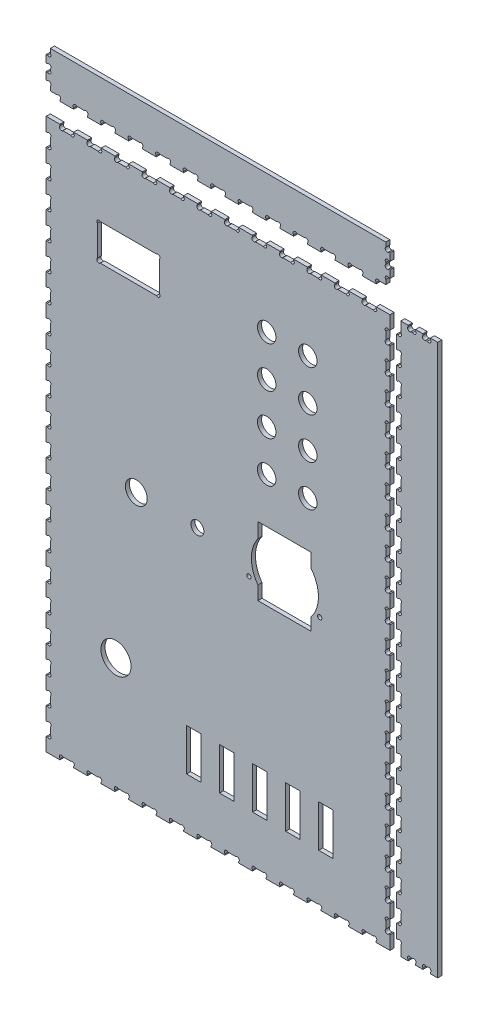
from build123d import *

# Parameters (mm, degrees)
CROQUIS2_W                = 251
CROQUIS2_H                = 402
CROQUIS2_R                = 11
CROQUIS2_R_2              = 1.55
CROQUIS2_R_3              = 4.75
CROQUIS2_R_4              = 8
CROQUIS2_R_5              = 6.75
CROQUIS2_W_2              = 10.6
CROQUIS2_H_2              = 30.7
SALIENTE_EXTRUIR2_DEPTH   = 3
CROQUIS4_W                = 3.05
CROQUIS4_H                = 9.804878049
CROQUIS4_H_2              = 9.804878048
CORTAR_EXTRUIR1_DEPTH     = 4
CROQUIS5_W                = 10.04
CROQUIS5_H                = 3.05
CORTAR_EXTRUIR2_DEPTH     = 4
CROQUIS12_W               = 30
CROQUIS12_H               = 402
SALIENTE_EXTRUIR3_DEPTH   = 3
CROQUIS12_W_2             = 251
CROQUIS12_H_2             = 30
SALIENTE_EXTRUIR3_2_DEPTH = 3
CROQUIS13_W               = 3.05
CROQUIS13_H               = 9.804878049
CROQUIS13_H_2             = 9.804878048
CORTAR_EXTRUIR8_DEPTH     = 4
CROQUIS14_W               = 5.39
CROQUIS14_H               = 3.05
CORTAR_EXTRUIR9_DEPTH     = 4
CROQUIS16_W               = 10.04
CROQUIS16_H               = 3.05
CORTAR_EXTRUIR10_DEPTH    = 4
CROQUIS18_W               = 3.05
CROQUIS18_H               = 5.39
CORTAR_EXTRUIR15_DEPTH    = 4
CROQUIS19_R               = 1.5
CORTAR_EXTRUIR12_DEPTH    = 4
CROQUIS20_R               = 1.5
CORTAR_EXTRUIR13_DEPTH    = 4
CROQUIS21_R               = 1.5
CORTAR_EXTRUIR14_DEPTH    = 4
CROQUIS23_R               = 1.5
CORTAR_EXTRUIR16_DEPTH    = 4
CROQUIS10_R               = 1.5
CORTAR_EXTRUIR6_DEPTH     = 4
CROQUIS11_R               = 1.5
CORTAR_EXTRUIR7_DEPTH     = 4


with BuildPart() as part:
    # Croquis2 → Saliente-Extruir2 (new body)
    with BuildSketch(Plane.XY):
        Rectangle(CROQUIS2_W, CROQUIS2_H)
        with Locations((-74.55, -116)):
            Circle(CROQUIS2_R, mode=Mode.SUBTRACT)
        with Locations((22.55, -15.8999)):
            Circle(CROQUIS2_R_2, mode=Mode.SUBTRACT)
        with Locations((74.25, -15.8999)):
            Circle(CROQUIS2_R_2, mode=Mode.SUBTRACT)
        with Locations((-15.0999, -4)):
            Circle(CROQUIS2_R_3, mode=Mode.SUBTRACT)
        with Locations((-59.72, -4)):
            Circle(CROQUIS2_R_4, mode=Mode.SUBTRACT)
        with Locations((65.5, 145)):
            Circle(CROQUIS2_R_5, mode=Mode.SUBTRACT)
        with Locations((35.5, 145)):
            Circle(CROQUIS2_R_5, mode=Mode.SUBTRACT)
        with Locations((35.5, 115)):
            Circle(CROQUIS2_R_5, mode=Mode.SUBTRACT)
        with Locations((65.5, 115)):
            Circle(CROQUIS2_R_5, mode=Mode.SUBTRACT)
        with Locations((35.5, 85)):
            Circle(CROQUIS2_R_5, mode=Mode.SUBTRACT)
        with Locations((65.5, 85)):
            Circle(CROQUIS2_R_5, mode=Mode.SUBTRACT)
        with Locations((35.5, 55)):
            Circle(CROQUIS2_R_5, mode=Mode.SUBTRACT)
        with Locations((65.5, 55)):
            Circle(CROQUIS2_R_5, mode=Mode.SUBTRACT)
        with Locations((-17.75, -148.35)):
            Rectangle(CROQUIS2_W_2, CROQUIS2_H_2, mode=Mode.SUBTRACT)
        with Locations((6.375, -148.35)):
            Rectangle(CROQUIS2_W_2, CROQUIS2_H_2, mode=Mode.SUBTRACT)
        with Locations((30.5, -148.35)):
            Rectangle(CROQUIS2_W_2, CROQUIS2_H_2, mode=Mode.SUBTRACT)
        with Locations((54.625, -148.35)):
            Rectangle(CROQUIS2_W_2, CROQUIS2_H_2, mode=Mode.SUBTRACT)
        with Locations((78.75, -148.35)):
            Rectangle(CROQUIS2_W_2, CROQUIS2_H_2, mode=Mode.SUBTRACT)
        with BuildLine():
            Line((29.1, 22), (67.7, 22))
            Line((67.7, 22), (67.7, 12.072751973))
            ThreePointArc((67.7, 12.072751973), (73.286, -3.5), (67.7, -19.072751973))
            Line((67.7, -19.072751973), (67.7, -28))
            Line((67.7, -28), (29.1, -28))
            Line((29.1, -28), (29.1, -18.084629032))
            ThreePointArc((29.1, -18.084629032), (24.286, -3.5), (29.1, 11.084629032))
            Line((29.1, 11.084629032), (29.1, 22))
        make_face(mode=Mode.SUBTRACT)
        with BuildLine():
            Line((-86.028579656, 154.1488), (-44.971220344, 154.1488))
            ThreePointArc((-44.971220344, 154.1488), (-42.8499, 154.1488), (-42.8499, 152.027479656))
            Line((-42.8499, 152.027479656), (-42.8499, 129.970120344))
            ThreePointArc((-42.8499, 129.970120344), (-42.8499, 127.8488), (-44.971220344, 127.8488))
            Line((-44.971220344, 127.8488), (-86.028579656, 127.8488))
            ThreePointArc((-86.028579656, 127.8488), (-88.1499, 127.8488), (-88.1499, 129.970120344))
            Line((-88.1499, 129.970120344), (-88.1499, 152.027479656))
            ThreePointArc((-88.1499, 152.027479656), (-88.1499, 154.1488), (-86.028579656, 154.1488))
        make_face(mode=Mode.SUBTRACT)
    extrude(amount=SALIENTE_EXTRUIR2_DEPTH)

    # Croquis4 → Cortar-Extruir1 (cut, through all)
    with BuildSketch(Plane.XY.offset(3)):
        with Locations((-123.975, 186.292682926)):
            Rectangle(CROQUIS4_W, CROQUIS4_H)
        with Locations((-123.975, 166.682926829)):
            Rectangle(CROQUIS4_W, CROQUIS4_H)
        with Locations((-123.975, 147.073170731)):
            Rectangle(CROQUIS4_W, CROQUIS4_H)
        with Locations((-123.975, 127.463414635)):
            Rectangle(CROQUIS4_W, CROQUIS4_H)
        with Locations((-123.975, 107.853658537)):
            Rectangle(CROQUIS4_W, CROQUIS4_H)
        with Locations((-123.975, 88.243902439)):
            Rectangle(CROQUIS4_W, CROQUIS4_H_2)
        with Locations((-123.975, 68.634146342)):
            Rectangle(CROQUIS4_W, CROQUIS4_H)
        with Locations((-123.975, 49.024390244)):
            Rectangle(CROQUIS4_W, CROQUIS4_H_2)
        with Locations((-123.975, 29.414634147)):
            Rectangle(CROQUIS4_W, CROQUIS4_H)
        with Locations((-123.975, 9.804878049)):
            Rectangle(CROQUIS4_W, CROQUIS4_H)
        with Locations((-123.975, -9.804878049)):
            Rectangle(CROQUIS4_W, CROQUIS4_H)
        with Locations((-123.975, -29.414634147)):
            Rectangle(CROQUIS4_W, CROQUIS4_H)
        with Locations((-123.975, -49.024390244)):
            Rectangle(CROQUIS4_W, CROQUIS4_H_2)
        with Locations((-123.975, -68.634146342)):
            Rectangle(CROQUIS4_W, CROQUIS4_H)
        with Locations((-123.975, -88.243902439)):
            Rectangle(CROQUIS4_W, CROQUIS4_H_2)
        with Locations((-123.975, -107.853658537)):
            Rectangle(CROQUIS4_W, CROQUIS4_H)
        with Locations((-123.975, -127.463414635)):
            Rectangle(CROQUIS4_W, CROQUIS4_H)
        with Locations((-123.975, -147.073170731)):
            Rectangle(CROQUIS4_W, CROQUIS4_H)
        with Locations((-123.975, -166.682926829)):
            Rectangle(CROQUIS4_W, CROQUIS4_H)
        with Locations((-123.975, -186.292682926)):
            Rectangle(CROQUIS4_W, CROQUIS4_H)
        with Locations((123.975, -186.292682926)):
            Rectangle(CROQUIS4_W, CROQUIS4_H)
        with Locations((123.975, -166.682926829)):
            Rectangle(CROQUIS4_W, CROQUIS4_H)
        with Locations((123.975, -147.073170731)):
            Rectangle(CROQUIS4_W, CROQUIS4_H)
        with Locations((123.975, -127.463414635)):
            Rectangle(CROQUIS4_W, CROQUIS4_H)
        with Locations((123.975, -107.853658537)):
            Rectangle(CROQUIS4_W, CROQUIS4_H)
        with Locations((123.975, -88.243902439)):
            Rectangle(CROQUIS4_W, CROQUIS4_H_2)
        with Locations((123.975, -68.634146342)):
            Rectangle(CROQUIS4_W, CROQUIS4_H)
        with Locations((123.975, -49.024390244)):
            Rectangle(CROQUIS4_W, CROQUIS4_H_2)
        with Locations((123.975, -29.414634147)):
            Rectangle(CROQUIS4_W, CROQUIS4_H)
        with Locations((123.975, -9.804878049)):
            Rectangle(CROQUIS4_W, CROQUIS4_H)
        with Locations((123.975, 9.804878049)):
            Rectangle(CROQUIS4_W, CROQUIS4_H)
        with Locations((123.975, 29.414634147)):
            Rectangle(CROQUIS4_W, CROQUIS4_H)
        with Locations((123.975, 49.024390244)):
            Rectangle(CROQUIS4_W, CROQUIS4_H_2)
        with Locations((123.975, 68.634146342)):
            Rectangle(CROQUIS4_W, CROQUIS4_H)
        with Locations((123.975, 88.243902439)):
            Rectangle(CROQUIS4_W, CROQUIS4_H_2)
        with Locations((123.975, 107.853658537)):
            Rectangle(CROQUIS4_W, CROQUIS4_H)
        with Locations((123.975, 127.463414635)):
            Rectangle(CROQUIS4_W, CROQUIS4_H)
        with Locations((123.975, 147.073170731)):
            Rectangle(CROQUIS4_W, CROQUIS4_H)
        with Locations((123.975, 166.682926829)):
            Rectangle(CROQUIS4_W, CROQUIS4_H)
        with Locations((123.975, 186.292682926)):
            Rectangle(CROQUIS4_W, CROQUIS4_H)
    extrude(amount=-CORTAR_EXTRUIR1_DEPTH, mode=Mode.SUBTRACT)

    # Croquis5 → Cortar-Extruir2 (cut, through all)
    with BuildSketch(Plane.XY.offset(3)):
        with Locations((-110.44, 199.475)):
            Rectangle(CROQUIS5_W, CROQUIS5_H)
        with Locations((-90.36, 199.475)):
            Rectangle(CROQUIS5_W, CROQUIS5_H)
        with Locations((-70.28, 199.475)):
            Rectangle(CROQUIS5_W, CROQUIS5_H)
        with Locations((-50.2, 199.475)):
            Rectangle(CROQUIS5_W, CROQUIS5_H)
        with Locations((-30.12, 199.475)):
            Rectangle(CROQUIS5_W, CROQUIS5_H)
        with Locations((-10.04, 199.475)):
            Rectangle(CROQUIS5_W, CROQUIS5_H)
        with Locations((10.04, 199.475)):
            Rectangle(CROQUIS5_W, CROQUIS5_H)
        with Locations((30.12, 199.475)):
            Rectangle(CROQUIS5_W, CROQUIS5_H)
        with Locations((50.2, 199.475)):
            Rectangle(CROQUIS5_W, CROQUIS5_H)
        with Locations((70.28, 199.475)):
            Rectangle(CROQUIS5_W, CROQUIS5_H)
        with Locations((90.36, 199.475)):
            Rectangle(CROQUIS5_W, CROQUIS5_H)
        with Locations((110.44, 199.475)):
            Rectangle(CROQUIS5_W, CROQUIS5_H)
        with Locations((110.44, -199.475)):
            Rectangle(CROQUIS5_W, CROQUIS5_H)
        with Locations((90.36, -199.475)):
            Rectangle(CROQUIS5_W, CROQUIS5_H)
        with Locations((70.28, -199.475)):
            Rectangle(CROQUIS5_W, CROQUIS5_H)
        with Locations((50.2, -199.475)):
            Rectangle(CROQUIS5_W, CROQUIS5_H)
        with Locations((30.12, -199.475)):
            Rectangle(CROQUIS5_W, CROQUIS5_H)
        with Locations((10.04, -199.475)):
            Rectangle(CROQUIS5_W, CROQUIS5_H)
        with Locations((-10.04, -199.475)):
            Rectangle(CROQUIS5_W, CROQUIS5_H)
        with Locations((-30.12, -199.475)):
            Rectangle(CROQUIS5_W, CROQUIS5_H)
        with Locations((-50.2, -199.475)):
            Rectangle(CROQUIS5_W, CROQUIS5_H)
        with Locations((-70.28, -199.475)):
            Rectangle(CROQUIS5_W, CROQUIS5_H)
        with Locations((-90.36, -199.475)):
            Rectangle(CROQUIS5_W, CROQUIS5_H)
        with Locations((-110.44, -199.475)):
            Rectangle(CROQUIS5_W, CROQUIS5_H)
    extrude(amount=-CORTAR_EXTRUIR2_DEPTH, mode=Mode.SUBTRACT)

    # Croquis10 → Cortar-Extruir6 (cut, through all)
    with BuildSketch(Plane.XY.offset(3)):
        with Locations((-123.510660172, 190.134461779)):
            Circle(CROQUIS10_R)
        with Locations((-123.510660172, 182.450904074)):
            Circle(CROQUIS10_R)
        with Locations((-123.510660172, 170.524705682)):
            Circle(CROQUIS10_R)
        with Locations((-123.510660172, 162.841147977)):
            Circle(CROQUIS10_R)
        with Locations((-123.510660172, 150.914949584)):
            Circle(CROQUIS10_R)
        with Locations((-123.510660172, 143.231391879)):
            Circle(CROQUIS10_R)
        with Locations((-123.510660172, 131.305193487)):
            Circle(CROQUIS10_R)
        with Locations((-123.510660172, 123.621635782)):
            Circle(CROQUIS10_R)
        with Locations((-123.510660172, 111.695437389)):
            Circle(CROQUIS10_R)
        with Locations((-123.510660172, 104.011879684)):
            Circle(CROQUIS10_R)
        with Locations((-123.510660172, 92.085681292)):
            Circle(CROQUIS10_R)
        with Locations((-123.510660172, 84.402123586)):
            Circle(CROQUIS10_R)
        with Locations((-123.510660172, 72.475925194)):
            Circle(CROQUIS10_R)
        with Locations((-123.510660172, 64.792367489)):
            Circle(CROQUIS10_R)
        with Locations((-123.510660172, 52.866169097)):
            Circle(CROQUIS10_R)
        with Locations((-123.510660172, 45.182611391)):
            Circle(CROQUIS10_R)
        with Locations((-123.510660172, 33.256412999)):
            Circle(CROQUIS10_R)
        with Locations((-123.510660172, 25.572855294)):
            Circle(CROQUIS10_R)
        with Locations((-123.510660172, 13.646656901)):
            Circle(CROQUIS10_R)
        with Locations((-123.510660172, 5.963099196)):
            Circle(CROQUIS10_R)
        with Locations((-123.510660172, -5.963099196)):
            Circle(CROQUIS10_R)
        with Locations((-123.510660172, -13.646656901)):
            Circle(CROQUIS10_R)
        with Locations((-123.510660172, -25.572855294)):
            Circle(CROQUIS10_R)
        with Locations((-123.510660172, -33.256412999)):
            Circle(CROQUIS10_R)
        with Locations((-123.510660172, -45.182611391)):
            Circle(CROQUIS10_R)
        with Locations((-123.510660172, -52.866169097)):
            Circle(CROQUIS10_R)
        with Locations((-123.510660172, -64.792367489)):
            Circle(CROQUIS10_R)
        with Locations((-123.510660172, -72.475925194)):
            Circle(CROQUIS10_R)
        with Locations((-123.510660172, -84.402123586)):
            Circle(CROQUIS10_R)
        with Locations((-123.510660172, -92.085681292)):
            Circle(CROQUIS10_R)
        with Locations((-123.510660172, -104.011879684)):
            Circle(CROQUIS10_R)
        with Locations((-123.510660172, -111.695437389)):
            Circle(CROQUIS10_R)
        with Locations((-123.510660172, -123.621635782)):
            Circle(CROQUIS10_R)
        with Locations((-123.510660172, -131.305193487)):
            Circle(CROQUIS10_R)
        with Locations((-123.510660172, -143.231391879)):
            Circle(CROQUIS10_R)
        with Locations((-123.510660172, -150.914949584)):
            Circle(CROQUIS10_R)
        with Locations((-123.510660172, -162.841147977)):
            Circle(CROQUIS10_R)
        with Locations((-123.510660172, -170.524705682)):
            Circle(CROQUIS10_R)
        with Locations((-123.510660172, -182.450904074)):
            Circle(CROQUIS10_R)
        with Locations((-123.510660172, -190.134461779)):
            Circle(CROQUIS10_R)
        with Locations((123.510660172, -190.134461779)):
            Circle(CROQUIS10_R)
        with Locations((123.510660172, -182.450904074)):
            Circle(CROQUIS10_R)
        with Locations((123.510660172, -170.524705682)):
            Circle(CROQUIS10_R)
        with Locations((123.510660172, -162.841147977)):
            Circle(CROQUIS10_R)
        with Locations((123.510660172, -150.914949584)):
            Circle(CROQUIS10_R)
        with Locations((123.510660172, -143.231391879)):
            Circle(CROQUIS10_R)
        with Locations((123.510660172, -131.305193487)):
            Circle(CROQUIS10_R)
        with Locations((123.510660172, -123.621635782)):
            Circle(CROQUIS10_R)
        with Locations((123.510660172, -111.695437389)):
            Circle(CROQUIS10_R)
        with Locations((123.510660172, -104.011879684)):
            Circle(CROQUIS10_R)
        with Locations((123.510660172, -92.085681292)):
            Circle(CROQUIS10_R)
        with Locations((123.510660172, -84.402123586)):
            Circle(CROQUIS10_R)
        with Locations((123.510660172, -72.475925194)):
            Circle(CROQUIS10_R)
        with Locations((123.510660172, -64.792367489)):
            Circle(CROQUIS10_R)
        with Locations((123.510660172, -52.866169097)):
            Circle(CROQUIS10_R)
        with Locations((123.510660172, -45.182611391)):
            Circle(CROQUIS10_R)
        with Locations((123.510660172, -33.256412999)):
            Circle(CROQUIS10_R)
        with Locations((123.510660172, -25.572855294)):
            Circle(CROQUIS10_R)
        with Locations((123.510660172, -13.646656901)):
            Circle(CROQUIS10_R)
        with Locations((123.510660172, -5.963099196)):
            Circle(CROQUIS10_R)
        with Locations((123.510660172, 5.963099196)):
            Circle(CROQUIS10_R)
        with Locations((123.510660172, 13.646656901)):
            Circle(CROQUIS10_R)
        with Locations((123.510660172, 25.572855294)):
            Circle(CROQUIS10_R)
        with Locations((123.510660172, 33.256412999)):
            Circle(CROQUIS10_R)
        with Locations((123.510660172, 45.182611391)):
            Circle(CROQUIS10_R)
        with Locations((123.510660172, 52.866169097)):
            Circle(CROQUIS10_R)
        with Locations((123.510660172, 64.792367489)):
            Circle(CROQUIS10_R)
        with Locations((123.510660172, 72.475925194)):
            Circle(CROQUIS10_R)
        with Locations((123.510660172, 84.402123586)):
            Circle(CROQUIS10_R)
        with Locations((123.510660172, 92.085681292)):
            Circle(CROQUIS10_R)
        with Locations((123.510660172, 104.011879684)):
            Circle(CROQUIS10_R)
        with Locations((123.510660172, 111.695437389)):
            Circle(CROQUIS10_R)
        with Locations((123.510660172, 123.621635782)):
            Circle(CROQUIS10_R)
        with Locations((123.510660172, 131.305193487)):
            Circle(CROQUIS10_R)
        with Locations((123.510660172, 143.231391879)):
            Circle(CROQUIS10_R)
        with Locations((123.510660172, 150.914949584)):
            Circle(CROQUIS10_R)
        with Locations((123.510660172, 162.841147977)):
            Circle(CROQUIS10_R)
        with Locations((123.510660172, 170.524705682)):
            Circle(CROQUIS10_R)
        with Locations((123.510660172, 182.450904074)):
            Circle(CROQUIS10_R)
        with Locations((123.510660172, 190.134461779)):
            Circle(CROQUIS10_R)
    extrude(amount=-CORTAR_EXTRUIR6_DEPTH, mode=Mode.SUBTRACT)

    # Croquis11 → Cortar-Extruir7 (cut, through all)
    with BuildSketch(Plane.XY.offset(3)):
        with Locations((-114.399339828, 199.010660172)):
            Circle(CROQUIS11_R)
        with Locations((-106.480660172, 199.010660172)):
            Circle(CROQUIS11_R)
        with Locations((-94.319339828, 199.010660172)):
            Circle(CROQUIS11_R)
        with Locations((-86.400660172, 199.010660172)):
            Circle(CROQUIS11_R)
        with Locations((-74.239339828, 199.010660172)):
            Circle(CROQUIS11_R)
        with Locations((-66.320660172, 199.010660172)):
            Circle(CROQUIS11_R)
        with Locations((-54.159339828, 199.010660172)):
            Circle(CROQUIS11_R)
        with Locations((-46.240660172, 199.010660172)):
            Circle(CROQUIS11_R)
        with Locations((-34.079339828, 199.010660172)):
            Circle(CROQUIS11_R)
        with Locations((-26.160660172, 199.010660172)):
            Circle(CROQUIS11_R)
        with Locations((-13.999339828, 199.010660172)):
            Circle(CROQUIS11_R)
        with Locations((-6.080660172, 199.010660172)):
            Circle(CROQUIS11_R)
        with Locations((6.080660172, 199.010660172)):
            Circle(CROQUIS11_R)
        with Locations((13.999339828, 199.010660172)):
            Circle(CROQUIS11_R)
        with Locations((26.160660172, 199.010660172)):
            Circle(CROQUIS11_R)
        with Locations((34.079339828, 199.010660172)):
            Circle(CROQUIS11_R)
        with Locations((46.240660172, 199.010660172)):
            Circle(CROQUIS11_R)
        with Locations((54.159339828, 199.010660172)):
            Circle(CROQUIS11_R)
        with Locations((66.320660172, 199.010660172)):
            Circle(CROQUIS11_R)
        with Locations((74.239339828, 199.010660172)):
            Circle(CROQUIS11_R)
        with Locations((86.400660172, 199.010660172)):
            Circle(CROQUIS11_R)
        with Locations((94.319339828, 199.010660172)):
            Circle(CROQUIS11_R)
        with Locations((106.480660172, 199.010660172)):
            Circle(CROQUIS11_R)
        with Locations((114.399339828, 199.010660172)):
            Circle(CROQUIS11_R)
        with Locations((114.399339828, -199.010660172)):
            Circle(CROQUIS11_R)
        with Locations((106.480660172, -199.010660172)):
            Circle(CROQUIS11_R)
        with Locations((94.319339828, -199.010660172)):
            Circle(CROQUIS11_R)
        with Locations((86.400660172, -199.010660172)):
            Circle(CROQUIS11_R)
        with Locations((74.239339828, -199.010660172)):
            Circle(CROQUIS11_R)
        with Locations((66.320660172, -199.010660172)):
            Circle(CROQUIS11_R)
        with Locations((54.159339828, -199.010660172)):
            Circle(CROQUIS11_R)
        with Locations((46.240660172, -199.010660172)):
            Circle(CROQUIS11_R)
        with Locations((34.079339828, -199.010660172)):
            Circle(CROQUIS11_R)
        with Locations((26.160660172, -199.010660172)):
            Circle(CROQUIS11_R)
        with Locations((13.999339828, -199.010660172)):
            Circle(CROQUIS11_R)
        with Locations((6.080660172, -199.010660172)):
            Circle(CROQUIS11_R)
        with Locations((-6.080660172, -199.010660172)):
            Circle(CROQUIS11_R)
        with Locations((-13.999339828, -199.010660172)):
            Circle(CROQUIS11_R)
        with Locations((-26.160660172, -199.010660172)):
            Circle(CROQUIS11_R)
        with Locations((-34.079339828, -199.010660172)):
            Circle(CROQUIS11_R)
        with Locations((-46.240660172, -199.010660172)):
            Circle(CROQUIS11_R)
        with Locations((-54.159339828, -199.010660172)):
            Circle(CROQUIS11_R)
        with Locations((-66.320660172, -199.010660172)):
            Circle(CROQUIS11_R)
        with Locations((-74.239339828, -199.010660172)):
            Circle(CROQUIS11_R)
        with Locations((-86.400660172, -199.010660172)):
            Circle(CROQUIS11_R)
        with Locations((-94.319339828, -199.010660172)):
            Circle(CROQUIS11_R)
        with Locations((-106.480660172, -199.010660172)):
            Circle(CROQUIS11_R)
        with Locations((-114.399339828, -199.010660172)):
            Circle(CROQUIS11_R)
    extrude(amount=-CORTAR_EXTRUIR7_DEPTH, mode=Mode.SUBTRACT)


with BuildPart() as body_2:
    # Croquis12 → Saliente-Extruir3 (new body)
    with BuildSketch(Plane.XY):
        with Locations((145.366831222, 0)):
            Rectangle(CROQUIS12_W, CROQUIS12_H)
    extrude(amount=SALIENTE_EXTRUIR3_DEPTH)

    # Croquis13 → Cortar-Extruir8 (cut, through all)
    with BuildSketch(Plane.XY.offset(3)):
        with Locations((131.891831222, 196.097560976)):
            Rectangle(CROQUIS13_W, CROQUIS13_H)
        with Locations((131.891831222, 176.487804878)):
            Rectangle(CROQUIS13_W, CROQUIS13_H_2)
        with Locations((131.891831222, 156.878048781)):
            Rectangle(CROQUIS13_W, CROQUIS13_H)
        with Locations((131.891831222, 137.268292683)):
            Rectangle(CROQUIS13_W, CROQUIS13_H_2)
        with Locations((131.891831222, 117.658536586)):
            Rectangle(CROQUIS13_W, CROQUIS13_H)
        with Locations((131.891831222, 98.048780488)):
            Rectangle(CROQUIS13_W, CROQUIS13_H)
        with Locations((131.891831222, 78.439024391)):
            Rectangle(CROQUIS13_W, CROQUIS13_H)
        with Locations((131.891831222, 58.829268293)):
            Rectangle(CROQUIS13_W, CROQUIS13_H)
        with Locations((131.891831222, 39.219512196)):
            Rectangle(CROQUIS13_W, CROQUIS13_H)
        with Locations((131.891831222, 19.609756098)):
            Rectangle(CROQUIS13_W, CROQUIS13_H)
        with Locations((131.891831222, 0)):
            Rectangle(CROQUIS13_W, CROQUIS13_H_2)
        with Locations((131.891831222, -19.609756098)):
            Rectangle(CROQUIS13_W, CROQUIS13_H)
        with Locations((131.891831222, -39.219512196)):
            Rectangle(CROQUIS13_W, CROQUIS13_H)
        with Locations((131.891831222, -58.829268293)):
            Rectangle(CROQUIS13_W, CROQUIS13_H)
        with Locations((131.891831222, -78.439024391)):
            Rectangle(CROQUIS13_W, CROQUIS13_H)
        with Locations((131.891831222, -98.048780488)):
            Rectangle(CROQUIS13_W, CROQUIS13_H)
        with Locations((131.891831222, -117.658536586)):
            Rectangle(CROQUIS13_W, CROQUIS13_H)
        with Locations((131.891831222, -137.268292683)):
            Rectangle(CROQUIS13_W, CROQUIS13_H_2)
        with Locations((131.891831222, -156.878048781)):
            Rectangle(CROQUIS13_W, CROQUIS13_H)
        with Locations((131.891831222, -176.487804878)):
            Rectangle(CROQUIS13_W, CROQUIS13_H_2)
        with Locations((131.891831222, -196.097560976)):
            Rectangle(CROQUIS13_W, CROQUIS13_H)
    extrude(amount=-CORTAR_EXTRUIR8_DEPTH, mode=Mode.SUBTRACT)

    # Croquis14 → Cortar-Extruir9 (cut, through all)
    with BuildSketch(Plane.XY.offset(3)):
        with Locations((141.501831222, 199.475)):
            Rectangle(CROQUIS14_W, CROQUIS14_H)
        with Locations((152.281831222, 199.475)):
            Rectangle(CROQUIS14_W, CROQUIS14_H)
        with Locations((152.281831222, -199.475)):
            Rectangle(CROQUIS14_W, CROQUIS14_H)
        with Locations((141.501831222, -199.475)):
            Rectangle(CROQUIS14_W, CROQUIS14_H)
    extrude(amount=-CORTAR_EXTRUIR9_DEPTH, mode=Mode.SUBTRACT)

    # Croquis19 → Cortar-Extruir12 (cut, through all)
    with BuildSketch(Plane.XY.offset(3)):
        with Locations((132.356171051, 192.255782123)):
            Circle(CROQUIS19_R)
        with Locations((132.356171051, 180.329583731)):
            Circle(CROQUIS19_R)
        with Locations((132.356171051, 172.646026025)):
            Circle(CROQUIS19_R)
        with Locations((132.356171051, 160.719827633)):
            Circle(CROQUIS19_R)
        with Locations((132.356171051, 153.036269928)):
            Circle(CROQUIS19_R)
        with Locations((132.356171051, 141.110071536)):
            Circle(CROQUIS19_R)
        with Locations((132.356171051, 133.42651383)):
            Circle(CROQUIS19_R)
        with Locations((132.356171051, 121.500315438)):
            Circle(CROQUIS19_R)
        with Locations((132.356171051, 113.816757733)):
            Circle(CROQUIS19_R)
        with Locations((132.356171051, 101.89055934)):
            Circle(CROQUIS19_R)
        with Locations((132.356171051, 94.207001635)):
            Circle(CROQUIS19_R)
        with Locations((132.356171051, 82.280803243)):
            Circle(CROQUIS19_R)
        with Locations((132.356171051, 74.597245538)):
            Circle(CROQUIS19_R)
        with Locations((132.356171051, 62.671047145)):
            Circle(CROQUIS19_R)
        with Locations((132.356171051, 54.98748944)):
            Circle(CROQUIS19_R)
        with Locations((132.356171051, 43.061291048)):
            Circle(CROQUIS19_R)
        with Locations((132.356171051, 35.377733343)):
            Circle(CROQUIS19_R)
        with Locations((132.356171051, 23.45153495)):
            Circle(CROQUIS19_R)
        with Locations((132.356171051, 15.767977245)):
            Circle(CROQUIS19_R)
        with Locations((132.356171051, 3.841778853)):
            Circle(CROQUIS19_R)
        with Locations((132.356171051, -3.841778853)):
            Circle(CROQUIS19_R)
        with Locations((132.356171051, -15.767977245)):
            Circle(CROQUIS19_R)
        with Locations((132.356171051, -23.45153495)):
            Circle(CROQUIS19_R)
        with Locations((132.356171051, -35.377733343)):
            Circle(CROQUIS19_R)
        with Locations((132.356171051, -43.061291048)):
            Circle(CROQUIS19_R)
        with Locations((132.356171051, -54.98748944)):
            Circle(CROQUIS19_R)
        with Locations((132.356171051, -62.671047145)):
            Circle(CROQUIS19_R)
        with Locations((132.356171051, -74.597245538)):
            Circle(CROQUIS19_R)
        with Locations((132.356171051, -82.280803243)):
            Circle(CROQUIS19_R)
        with Locations((132.356171051, -94.207001635)):
            Circle(CROQUIS19_R)
        with Locations((132.356171051, -101.89055934)):
            Circle(CROQUIS19_R)
        with Locations((132.356171051, -113.816757733)):
            Circle(CROQUIS19_R)
        with Locations((132.356171051, -121.500315438)):
            Circle(CROQUIS19_R)
        with Locations((132.356171051, -133.42651383)):
            Circle(CROQUIS19_R)
        with Locations((132.356171051, -141.110071536)):
            Circle(CROQUIS19_R)
        with Locations((132.356171051, -153.036269928)):
            Circle(CROQUIS19_R)
        with Locations((132.356171051, -160.719827633)):
            Circle(CROQUIS19_R)
        with Locations((132.356171051, -172.646026025)):
            Circle(CROQUIS19_R)
        with Locations((132.356171051, -180.329583731)):
            Circle(CROQUIS19_R)
        with Locations((132.356171051, -192.255782123)):
            Circle(CROQUIS19_R)
    extrude(amount=-CORTAR_EXTRUIR12_DEPTH, mode=Mode.SUBTRACT)

    # Croquis20 → Cortar-Extruir13 (cut, through all)
    with BuildSketch(Plane.XY.offset(3)):
        with Locations((139.867491394, 199.010660172)):
            Circle(CROQUIS20_R)
        with Locations((143.136171051, 199.010660172)):
            Circle(CROQUIS20_R)
        with Locations((153.916171051, 199.010660172)):
            Circle(CROQUIS20_R)
        with Locations((150.647491394, 199.010660172)):
            Circle(CROQUIS20_R)
        with Locations((153.916171051, -199.010660172)):
            Circle(CROQUIS20_R)
        with Locations((150.647491394, -199.010660172)):
            Circle(CROQUIS20_R)
        with Locations((139.867491394, -199.010660172)):
            Circle(CROQUIS20_R)
        with Locations((143.136171051, -199.010660172)):
            Circle(CROQUIS20_R)
    extrude(amount=-CORTAR_EXTRUIR13_DEPTH, mode=Mode.SUBTRACT)


with BuildPart() as body_3:
    # Croquis12 → Saliente-Extruir3 2 (new body)
    with BuildSketch(Plane.XY):
        with Locations((0, 230.459584674)):
            Rectangle(CROQUIS12_W_2, CROQUIS12_H_2)
    extrude(amount=SALIENTE_EXTRUIR3_2_DEPTH)

    # Croquis16 → Cortar-Extruir10 (cut, through all)
    with BuildSketch(Plane.XY.offset(3)):
        with Locations((-120.48, 216.984584674)):
            Rectangle(CROQUIS16_W, CROQUIS16_H)
        with Locations((-100.4, 216.984584674)):
            Rectangle(CROQUIS16_W, CROQUIS16_H)
        with Locations((-80.32, 216.984584674)):
            Rectangle(CROQUIS16_W, CROQUIS16_H)
        with Locations((-60.24, 216.984584674)):
            Rectangle(CROQUIS16_W, CROQUIS16_H)
        with Locations((-40.16, 216.984584674)):
            Rectangle(CROQUIS16_W, CROQUIS16_H)
        with Locations((-20.08, 216.984584674)):
            Rectangle(CROQUIS16_W, CROQUIS16_H)
        with Locations((0, 216.984584674)):
            Rectangle(CROQUIS16_W, CROQUIS16_H)
        with Locations((20.08, 216.984584674)):
            Rectangle(CROQUIS16_W, CROQUIS16_H)
        with Locations((40.16, 216.984584674)):
            Rectangle(CROQUIS16_W, CROQUIS16_H)
        with Locations((60.24, 216.984584674)):
            Rectangle(CROQUIS16_W, CROQUIS16_H)
        with Locations((80.32, 216.984584674)):
            Rectangle(CROQUIS16_W, CROQUIS16_H)
        with Locations((100.4, 216.984584674)):
            Rectangle(CROQUIS16_W, CROQUIS16_H)
        with Locations((120.48, 216.984584674)):
            Rectangle(CROQUIS16_W, CROQUIS16_H)
    extrude(amount=-CORTAR_EXTRUIR10_DEPTH, mode=Mode.SUBTRACT)

    # Croquis18 → Cortar-Extruir15 (cut, through all)
    with BuildSketch(Plane.XY.offset(3)):
        with Locations((123.975, 221.204584674)):
            Rectangle(CROQUIS18_W, CROQUIS18_H)
        with Locations((123.975, 242.764584674)):
            Rectangle(CROQUIS18_W, CROQUIS18_H)
        with Locations((123.975, 231.984584674)):
            Rectangle(CROQUIS18_W, CROQUIS18_H)
        with Locations((-123.975, 231.984584674)):
            Rectangle(CROQUIS18_W, CROQUIS18_H)
        with Locations((-123.975, 242.764584674)):
            Rectangle(CROQUIS18_W, CROQUIS18_H)
        with Locations((-123.975, 221.204584674)):
            Rectangle(CROQUIS18_W, CROQUIS18_H)
    extrude(amount=-CORTAR_EXTRUIR15_DEPTH, mode=Mode.SUBTRACT)

    # Croquis21 → Cortar-Extruir14 (cut, through all)
    with BuildSketch(Plane.XY.offset(3)):
        with Locations((-116.520660172, 217.448924502)):
            Circle(CROQUIS21_R)
        with Locations((-104.359339828, 217.448924502)):
            Circle(CROQUIS21_R)
        with Locations((-96.440660172, 217.448924502)):
            Circle(CROQUIS21_R)
        with Locations((-76.360660172, 217.448924502)):
            Circle(CROQUIS21_R)
        with Locations((-84.279339828, 217.448924502)):
            Circle(CROQUIS21_R)
        with Locations((-56.280660172, 217.448924502)):
            Circle(CROQUIS21_R)
        with Locations((-64.199339828, 217.448924502)):
            Circle(CROQUIS21_R)
        with Locations((-36.200660172, 217.448924502)):
            Circle(CROQUIS21_R)
        with Locations((-44.119339828, 217.448924502)):
            Circle(CROQUIS21_R)
        with Locations((-16.120660172, 217.448924502)):
            Circle(CROQUIS21_R)
        with Locations((-24.039339828, 217.448924502)):
            Circle(CROQUIS21_R)
        with Locations((3.959339828, 217.448924502)):
            Circle(CROQUIS21_R)
        with Locations((-3.959339828, 217.448924502)):
            Circle(CROQUIS21_R)
        with Locations((24.039339828, 217.448924502)):
            Circle(CROQUIS21_R)
        with Locations((16.120660172, 217.448924502)):
            Circle(CROQUIS21_R)
        with Locations((44.119339828, 217.448924502)):
            Circle(CROQUIS21_R)
        with Locations((36.200660172, 217.448924502)):
            Circle(CROQUIS21_R)
        with Locations((64.199339828, 217.448924502)):
            Circle(CROQUIS21_R)
        with Locations((56.280660172, 217.448924502)):
            Circle(CROQUIS21_R)
        with Locations((84.279339828, 217.448924502)):
            Circle(CROQUIS21_R)
        with Locations((76.360660172, 217.448924502)):
            Circle(CROQUIS21_R)
        with Locations((104.359339828, 217.448924502)):
            Circle(CROQUIS21_R)
        with Locations((96.440660172, 217.448924502)):
            Circle(CROQUIS21_R)
        with Locations((116.520660172, 217.448924502)):
            Circle(CROQUIS21_R)
    extrude(amount=-CORTAR_EXTRUIR14_DEPTH, mode=Mode.SUBTRACT)

    # Croquis23 → Cortar-Extruir16 (cut, through all)
    with BuildSketch(Plane.XY.offset(3)):
        with Locations((-123.510660172, 222.838924502)):
            Circle(CROQUIS23_R)
        with Locations((-123.510660172, 230.350244846)):
            Circle(CROQUIS23_R)
        with Locations((-123.510660172, 233.618924502)):
            Circle(CROQUIS23_R)
        with Locations((-123.510660172, 241.130244846)):
            Circle(CROQUIS23_R)
        with Locations((123.510660172, 222.838924502)):
            Circle(CROQUIS23_R)
        with Locations((123.510660172, 230.350244846)):
            Circle(CROQUIS23_R)
        with Locations((123.510660172, 233.618924502)):
            Circle(CROQUIS23_R)
        with Locations((123.510660172, 241.130244846)):
            Circle(CROQUIS23_R)
    extrude(amount=-CORTAR_EXTRUIR16_DEPTH, mode=Mode.SUBTRACT)


solid = Compound([part.part, body_2.part, body_3.part])
